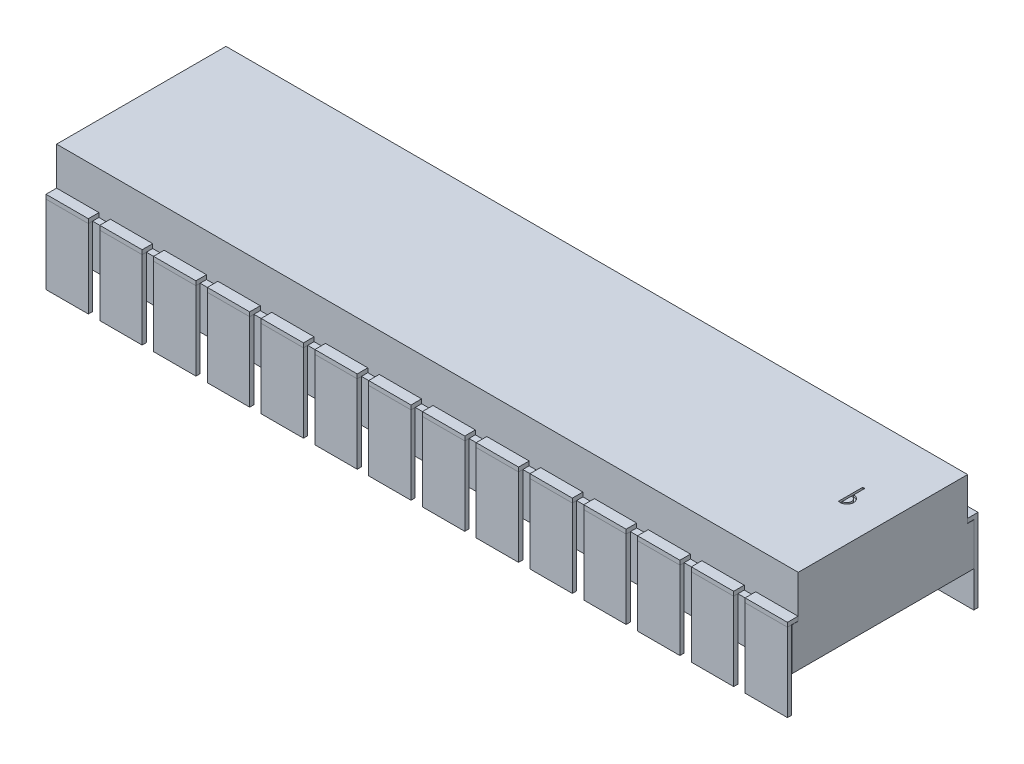
from build123d import *

# Parameters (mm, degrees)
SKETCH1_W              = 35.03
SKETCH1_H              = 8.6
BOSS_EXTRUDE1_DEPTH    = 2
SKETCH2_W              = 35.03
SKETCH2_H              = 8
BOSS_EXTRUDE2_DEPTH    = 2
CUT_EXTRUDE2_DEPTH     = 0.1
SKETCH5_W              = 2
SKETCH5_H              = 0.2
BOSS_EXTRUDE3_DEPTH    = 0.5
SKETCH7_W              = 2
SKETCH7_H              = 3.7
BOSS_EXTRUDE4_DEPTH    = 0.2
BOSS_EXTRUDE4_2_DEPTH  = 0.2
BOSS_EXTRUDE4_3_DEPTH  = 0.2
BOSS_EXTRUDE4_4_DEPTH  = 0.2
BOSS_EXTRUDE4_5_DEPTH  = 0.2
BOSS_EXTRUDE4_6_DEPTH  = 0.2
BOSS_EXTRUDE4_7_DEPTH  = 0.2
BOSS_EXTRUDE4_8_DEPTH  = 0.2
BOSS_EXTRUDE4_9_DEPTH  = 0.2
BOSS_EXTRUDE4_10_DEPTH = 0.2
BOSS_EXTRUDE4_11_DEPTH = 0.2
BOSS_EXTRUDE4_12_DEPTH = 0.2
BOSS_EXTRUDE4_13_DEPTH = 0.2
BOSS_EXTRUDE4_14_DEPTH = 0.2


with BuildPart() as part:
    # Sketch1 → Boss-Extrude1 (new body)
    with BuildSketch(Plane(origin=(0, 0, 0), x_dir=(1, 0, 0), z_dir=(0, 1, 0))):
        with Locations((1.883422091, 0.359763314)):
            Rectangle(SKETCH1_W, SKETCH1_H)
    extrude(amount=BOSS_EXTRUDE1_DEPTH)

    # Sketch2 → Boss-Extrude2 (add)
    with BuildSketch(Plane(origin=(0, 2, 0), x_dir=(1, 0, 0), z_dir=(0, 1, 0))):
        with Locations((1.883422091, 0.359763314)):
            Rectangle(SKETCH2_W, SKETCH2_H)
    extrude(amount=BOSS_EXTRUDE2_DEPTH)

    # Sketch4 → Cut-Extrude2 (cut)
    with BuildSketch(Plane(origin=(0, 4, 0), x_dir=(1, 0, 0), z_dir=(0, 1, 0))):
        with BuildLine():
            Line((17.442207596, 1.363598943), (17.442207596, 0.209523646))
            Line((17.442207596, 0.209523646), (17.491154421, 0.209523646))
            ThreePointArc((17.491154421, 0.209523646), (17.854111597, 0.49611752), (17.540101245, 0.835634029))
            Line((17.540101245, 0.835634029), (17.540101245, 1.363598943))
            Line((17.540101245, 1.363598943), (17.442207596, 1.363598943))
        make_face()
        with BuildLine():
            Line((17.540101245, 0.731661436), (17.540101245, 0.292140929))
            ThreePointArc((17.540101245, 0.292140929), (17.759861499, 0.511901182), (17.540101245, 0.731661436))
        make_face(mode=Mode.SUBTRACT)
    extrude(amount=-CUT_EXTRUDE2_DEPTH, mode=Mode.SUBTRACT)

    # Sketch5 → Boss-Extrude3 (add)
    with BuildSketch(Plane.XY.offset(3.640236686)):
        with Locations((-12.091577909, 2.1)):
            Rectangle(SKETCH5_W, SKETCH5_H)
        with Locations((-14.631577909, 2.1)):
            Rectangle(SKETCH5_W, SKETCH5_H)
        with Locations((-9.551577909, 2.1)):
            Rectangle(SKETCH5_W, SKETCH5_H)
        with Locations((-7.011577909, 2.1)):
            Rectangle(SKETCH5_W, SKETCH5_H)
        with Locations((-4.471577909, 2.1)):
            Rectangle(SKETCH5_W, SKETCH5_H)
        with Locations((-1.931577909, 2.1)):
            Rectangle(SKETCH5_W, SKETCH5_H)
        with Locations((0.608422091, 2.1)):
            Rectangle(SKETCH5_W, SKETCH5_H)
        with Locations((3.148422091, 2.1)):
            Rectangle(SKETCH5_W, SKETCH5_H)
        with Locations((5.688422091, 2.1)):
            Rectangle(SKETCH5_W, SKETCH5_H)
        with Locations((8.228422091, 2.1)):
            Rectangle(SKETCH5_W, SKETCH5_H)
        with Locations((10.768422091, 2.1)):
            Rectangle(SKETCH5_W, SKETCH5_H)
        with Locations((13.308422091, 2.1)):
            Rectangle(SKETCH5_W, SKETCH5_H)
        with Locations((15.848422091, 2.1)):
            Rectangle(SKETCH5_W, SKETCH5_H)
        with Locations((18.388422091, 2.1)):
            Rectangle(SKETCH5_W, SKETCH5_H)
    boss_extrude3 = extrude(amount=BOSS_EXTRUDE3_DEPTH)

    # Mirror1: Boss-Extrude3 across plane
    add(boss_extrude3.mirror(Plane.XY.offset(-0.359763314)))


with BuildPart() as body_2:
    # Sketch7 → Boss-Extrude4 (new body)
    with BuildSketch(Plane.XY.offset(4.140236686)):
        with Locations((-12.091577909, 0.15)):
            Rectangle(SKETCH7_W, SKETCH7_H)
    boss_extrude4 = extrude(amount=-BOSS_EXTRUDE4_DEPTH)


with BuildPart() as body_3:
    # Sketch7 → Boss-Extrude4 2 (new body)
    with BuildSketch(Plane.XY.offset(4.140236686)):
        Polygon((-15.631577909, 2), (-15.631577909, -1.7), (-13.631577909, -1.7), (-13.631577909, 2), (-13.631577909, 2.2), (-15.631577909, 2.2), align=None)
    boss_extrude4_2 = extrude(amount=-BOSS_EXTRUDE4_2_DEPTH)


with BuildPart() as body_4:
    # Sketch7 → Boss-Extrude4 3 (new body)
    with BuildSketch(Plane.XY.offset(4.140236686)):
        with Locations((-9.551577909, 0.15)):
            Rectangle(SKETCH7_W, SKETCH7_H)
    boss_extrude4_3 = extrude(amount=-BOSS_EXTRUDE4_3_DEPTH)


with BuildPart() as body_5:
    # Sketch7 → Boss-Extrude4 4 (new body)
    with BuildSketch(Plane.XY.offset(4.140236686)):
        with Locations((-7.011577909, 0.15)):
            Rectangle(SKETCH7_W, SKETCH7_H)
    boss_extrude4_4 = extrude(amount=-BOSS_EXTRUDE4_4_DEPTH)


with BuildPart() as body_6:
    # Sketch7 → Boss-Extrude4 5 (new body)
    with BuildSketch(Plane.XY.offset(4.140236686)):
        with Locations((-4.471577909, 0.15)):
            Rectangle(SKETCH7_W, SKETCH7_H)
    boss_extrude4_5 = extrude(amount=-BOSS_EXTRUDE4_5_DEPTH)


with BuildPart() as body_7:
    # Sketch7 → Boss-Extrude4 6 (new body)
    with BuildSketch(Plane.XY.offset(4.140236686)):
        with Locations((-1.931577909, 0.15)):
            Rectangle(SKETCH7_W, SKETCH7_H)
    boss_extrude4_6 = extrude(amount=-BOSS_EXTRUDE4_6_DEPTH)


with BuildPart() as body_8:
    # Sketch7 → Boss-Extrude4 7 (new body)
    with BuildSketch(Plane.XY.offset(4.140236686)):
        with Locations((0.608422091, 0.15)):
            Rectangle(SKETCH7_W, SKETCH7_H)
    boss_extrude4_7 = extrude(amount=-BOSS_EXTRUDE4_7_DEPTH)


with BuildPart() as body_9:
    # Sketch7 → Boss-Extrude4 8 (new body)
    with BuildSketch(Plane.XY.offset(4.140236686)):
        with Locations((3.148422091, 0.15)):
            Rectangle(SKETCH7_W, SKETCH7_H)
    boss_extrude4_8 = extrude(amount=-BOSS_EXTRUDE4_8_DEPTH)


with BuildPart() as body_10:
    # Sketch7 → Boss-Extrude4 9 (new body)
    with BuildSketch(Plane.XY.offset(4.140236686)):
        with Locations((5.688422091, 0.15)):
            Rectangle(SKETCH7_W, SKETCH7_H)
    boss_extrude4_9 = extrude(amount=-BOSS_EXTRUDE4_9_DEPTH)


with BuildPart() as body_11:
    # Sketch7 → Boss-Extrude4 10 (new body)
    with BuildSketch(Plane.XY.offset(4.140236686)):
        with Locations((8.228422091, 0.15)):
            Rectangle(SKETCH7_W, SKETCH7_H)
    boss_extrude4_10 = extrude(amount=-BOSS_EXTRUDE4_10_DEPTH)


with BuildPart() as body_12:
    # Sketch7 → Boss-Extrude4 11 (new body)
    with BuildSketch(Plane.XY.offset(4.140236686)):
        with Locations((10.768422091, 0.15)):
            Rectangle(SKETCH7_W, SKETCH7_H)
    boss_extrude4_11 = extrude(amount=-BOSS_EXTRUDE4_11_DEPTH)


with BuildPart() as body_13:
    # Sketch7 → Boss-Extrude4 12 (new body)
    with BuildSketch(Plane.XY.offset(4.140236686)):
        with Locations((13.308422091, 0.15)):
            Rectangle(SKETCH7_W, SKETCH7_H)
    boss_extrude4_12 = extrude(amount=-BOSS_EXTRUDE4_12_DEPTH)


with BuildPart() as body_14:
    # Sketch7 → Boss-Extrude4 13 (new body)
    with BuildSketch(Plane.XY.offset(4.140236686)):
        with Locations((15.848422091, 0.15)):
            Rectangle(SKETCH7_W, SKETCH7_H)
    boss_extrude4_13 = extrude(amount=-BOSS_EXTRUDE4_13_DEPTH)


with BuildPart() as body_15:
    # Sketch7 → Boss-Extrude4 14 (new body)
    with BuildSketch(Plane.XY.offset(4.140236686)):
        with Locations((18.388422091, 0.15)):
            Rectangle(SKETCH7_W, SKETCH7_H)
    boss_extrude4_14 = extrude(amount=-BOSS_EXTRUDE4_14_DEPTH)


with BuildPart() as part_1:
    add(part.part)

    # Mirror2: Boss-Extrude4, Boss-Extrude4 2, Boss-Extrude4 3, Boss-Extrude4 4, Boss-Extrude4 5, Boss-Extrude4 6, Boss-Extrude4 7, Boss-Extrude4 8, Boss-Extrude4 9, Boss-Extrude4 10, Boss-Extrude4 11, Boss-Extrude4 12, Boss-Extrude4 13, Boss-Extrude4 14 across plane
    add(boss_extrude4.mirror(Plane.XY.offset(-0.359763314)))
    add(boss_extrude4_2.mirror(Plane.XY.offset(-0.359763314)))
    add(boss_extrude4_3.mirror(Plane.XY.offset(-0.359763314)))
    add(boss_extrude4_4.mirror(Plane.XY.offset(-0.359763314)))
    add(boss_extrude4_5.mirror(Plane.XY.offset(-0.359763314)))
    add(boss_extrude4_6.mirror(Plane.XY.offset(-0.359763314)))
    add(boss_extrude4_7.mirror(Plane.XY.offset(-0.359763314)))
    add(boss_extrude4_8.mirror(Plane.XY.offset(-0.359763314)))
    add(boss_extrude4_9.mirror(Plane.XY.offset(-0.359763314)))
    add(boss_extrude4_10.mirror(Plane.XY.offset(-0.359763314)))
    add(boss_extrude4_11.mirror(Plane.XY.offset(-0.359763314)))
    add(boss_extrude4_12.mirror(Plane.XY.offset(-0.359763314)))
    add(boss_extrude4_13.mirror(Plane.XY.offset(-0.359763314)))
    add(boss_extrude4_14.mirror(Plane.XY.offset(-0.359763314)))


solid = Compound([body_2.part, body_3.part, body_4.part, body_5.part, body_6.part, body_7.part, body_8.part, body_9.part, body_10.part, body_11.part, body_12.part, body_13.part, body_14.part, body_15.part, part_1.part])
